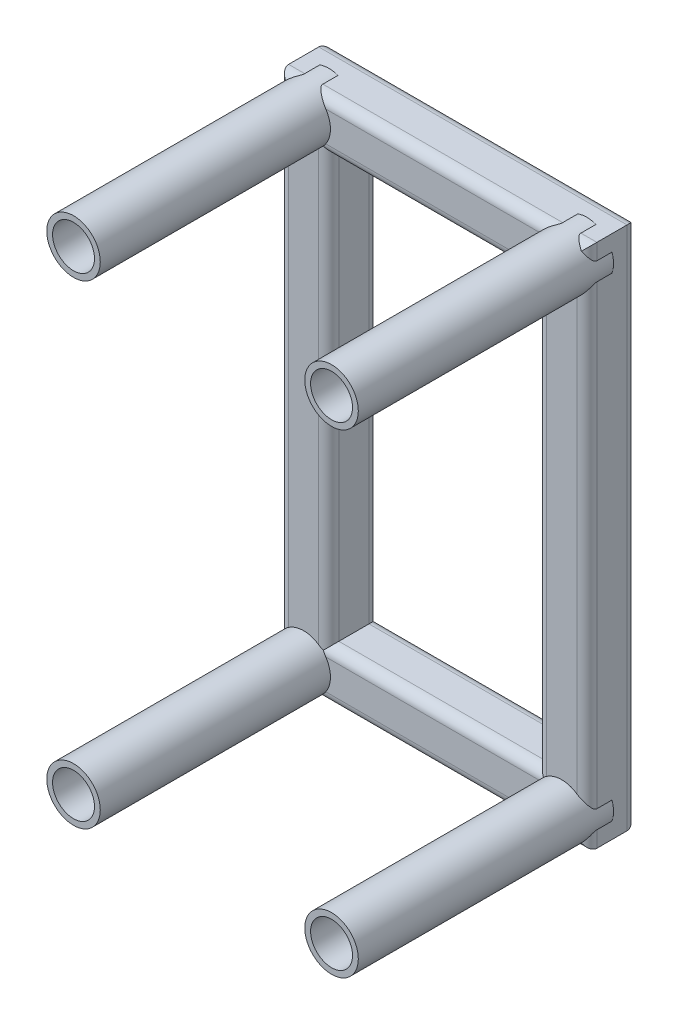
from build123d import *

# Parameters (mm, degrees)
STRUCTURAL_MEMBER1_DEPTH      = 204.012968698
STRUCTURAL_MEMBER1_DEPTH_BACK = 15.142135624
STRUCTURAL_MEMBER1_2_DEPTH    = 132.981628501
STRUCTURAL_MEMBER1_3_DEPTH    = 219.155104322
STRUCTURAL_MEMBER1_4_DEPTH    = 132.981628501
SKETCH19_R                    = 10.65
SKETCH19_R_2                  = 8.35
STRUCTURAL_MEMBER2_DEPTH      = 101.6
SKETCH19_ON_SEGMENT_2_R       = 10.65
SKETCH19_ON_SEGMENT_2_R_2     = 8.35
STRUCTURAL_MEMBER2_2_DEPTH    = 101.6
SKETCH19_ON_SEGMENT_3_R       = 10.65
SKETCH19_ON_SEGMENT_3_R_2     = 8.35
STRUCTURAL_MEMBER2_3_DEPTH    = 101.6
SKETCH19_ON_SEGMENT_4_R       = 10.65
SKETCH19_ON_SEGMENT_4_R_2     = 8.35
STRUCTURAL_MEMBER2_4_DEPTH    = 101.6


with BuildPart() as part:
    # Sketch18 → Structural Member1 (new, two sides)
    with BuildSketch(Plane(origin=(-51.348678627, 94.435416537, 0), x_dir=(1, 0, 0), z_dir=(0, -1, 0))) as structural_member1_sk:
        with BuildLine():
            Line((-6, -10), (6, -10))
            ThreePointArc((6, -10), (8.828427125, -8.828427125), (10, -6))
            Line((10, -6), (10, 6))
            ThreePointArc((10, 6), (8.828427125, 8.828427125), (6, 10))
            Line((6, 10), (-6, 10))
            ThreePointArc((-6, 10), (-8.828427125, 8.828427125), (-10, 6))
            Line((-10, 6), (-10, -6))
            ThreePointArc((-10, -6), (-8.828427125, -8.828427125), (-6, -10))
        make_face()
        with BuildLine():
            Line((-6, -8), (6, -8))
            ThreePointArc((6, -8), (7.414213562, -7.414213562), (8, -6))
            Line((8, -6), (8, 6))
            ThreePointArc((8, 6), (7.414213562, 7.414213562), (6, 8))
            Line((6, 8), (-6, 8))
            ThreePointArc((-6, 8), (-7.414213562, 7.414213562), (-8, 6))
            Line((-8, 6), (-8, -6))
            ThreePointArc((-8, -6), (-7.414213562, -7.414213562), (-6, -8))
        make_face(mode=Mode.SUBTRACT)
    extrude(amount=STRUCTURAL_MEMBER1_DEPTH)
    extrude(structural_member1_sk.sketch, amount=-STRUCTURAL_MEMBER1_DEPTH_BACK)

    # Structural Member1 mitre 1
    split(bisect_by=Plane(origin=(-51.348678627, 94.435416537, 0), x_dir=(0.707106781, -0.707106781, 0), z_dir=(-0.707106781, -0.707106781, 0)), keep=Keep.TOP)

    # Structural Member1 mitre 2
    split(bisect_by=Plane(origin=(-51.348678627, -94.435416537, 0), x_dir=(-0.707106781, -0.707106781, 0), z_dir=(-0.707106781, 0.707106781, 0)), keep=Keep.TOP)


with BuildPart() as body_2:
    # Sketch18 on segment 2 (carried to segment 2) → Structural Member1 2 (new body)
    with BuildSketch(Plane(origin=(-66.490814251, -94.435416537, 0), x_dir=(0, 1, 0), z_dir=(1, 0, 0))):
        with BuildLine():
            Line((-6, -10), (6, -10))
            ThreePointArc((6, -10), (8.828427125, -8.828427125), (10, -6))
            Line((10, -6), (10, 6))
            ThreePointArc((10, 6), (8.828427125, 8.828427125), (6, 10))
            Line((6, 10), (-6, 10))
            ThreePointArc((-6, 10), (-8.828427125, 8.828427125), (-10, 6))
            Line((-10, 6), (-10, -6))
            ThreePointArc((-10, -6), (-8.828427125, -8.828427125), (-6, -10))
        make_face()
        with BuildLine():
            Line((-6, -8), (6, -8))
            ThreePointArc((6, -8), (7.414213562, -7.414213562), (8, -6))
            Line((8, -6), (8, 6))
            ThreePointArc((8, 6), (7.414213562, 7.414213562), (6, 8))
            Line((6, 8), (-6, 8))
            ThreePointArc((-6, 8), (-7.414213562, 7.414213562), (-8, 6))
            Line((-8, 6), (-8, -6))
            ThreePointArc((-8, -6), (-7.414213562, -7.414213562), (-6, -8))
        make_face(mode=Mode.SUBTRACT)
    extrude(amount=STRUCTURAL_MEMBER1_2_DEPTH)

    # Structural Member1 2 mitre 1
    split(bisect_by=Plane(origin=(-51.348678627, -94.435416537, 0), x_dir=(0.707106781, 0.707106781, 0), z_dir=(0.707106781, -0.707106781, 0)), keep=Keep.TOP)

    # Structural Member1 2 mitre 2
    split(bisect_by=Plane(origin=(51.348678627, -94.435416537, 0), x_dir=(0.707106781, -0.707106781, 0), z_dir=(-0.707106781, -0.707106781, 0)), keep=Keep.TOP)


with BuildPart() as body_3:
    # Sketch18 on segment 3 (carried to segment 3) → Structural Member1 3 (new body)
    with BuildSketch(Plane(origin=(51.348678627, -109.577552161, 0), x_dir=(-1, 0, 0), z_dir=(0, 1, 0))):
        with BuildLine():
            Line((-6, -10), (6, -10))
            ThreePointArc((6, -10), (8.828427125, -8.828427125), (10, -6))
            Line((10, -6), (10, 6))
            ThreePointArc((10, 6), (8.828427125, 8.828427125), (6, 10))
            Line((6, 10), (-6, 10))
            ThreePointArc((-6, 10), (-8.828427125, 8.828427125), (-10, 6))
            Line((-10, 6), (-10, -6))
            ThreePointArc((-10, -6), (-8.828427125, -8.828427125), (-6, -10))
        make_face()
        with BuildLine():
            Line((-6, -8), (6, -8))
            ThreePointArc((6, -8), (7.414213562, -7.414213562), (8, -6))
            Line((8, -6), (8, 6))
            ThreePointArc((8, 6), (7.414213562, 7.414213562), (6, 8))
            Line((6, 8), (-6, 8))
            ThreePointArc((-6, 8), (-7.414213562, 7.414213562), (-8, 6))
            Line((-8, 6), (-8, -6))
            ThreePointArc((-8, -6), (-7.414213562, -7.414213562), (-6, -8))
        make_face(mode=Mode.SUBTRACT)
    extrude(amount=STRUCTURAL_MEMBER1_3_DEPTH)

    # Structural Member1 3 mitre 1
    split(bisect_by=Plane(origin=(51.348678627, 94.435416537, 0), x_dir=(0.707106781, 0.707106781, 0), z_dir=(0.707106781, -0.707106781, 0)), keep=Keep.TOP)

    # Structural Member1 3 mitre 2
    split(bisect_by=Plane(origin=(51.348678627, -94.435416537, 0), x_dir=(-0.707106781, 0.707106781, 0), z_dir=(0.707106781, 0.707106781, 0)), keep=Keep.TOP)


with BuildPart() as body_4:
    # Sketch18 on segment 4 (carried to segment 4) → Structural Member1 4 (new body)
    with BuildSketch(Plane(origin=(66.490814251, 94.435416537, 0), x_dir=(0, -1, 0), z_dir=(-1, 0, 0))):
        with BuildLine():
            Line((-6, -10), (6, -10))
            ThreePointArc((6, -10), (8.828427125, -8.828427125), (10, -6))
            Line((10, -6), (10, 6))
            ThreePointArc((10, 6), (8.828427125, 8.828427125), (6, 10))
            Line((6, 10), (-6, 10))
            ThreePointArc((-6, 10), (-8.828427125, 8.828427125), (-10, 6))
            Line((-10, 6), (-10, -6))
            ThreePointArc((-10, -6), (-8.828427125, -8.828427125), (-6, -10))
        make_face()
        with BuildLine():
            Line((-6, -8), (6, -8))
            ThreePointArc((6, -8), (7.414213562, -7.414213562), (8, -6))
            Line((8, -6), (8, 6))
            ThreePointArc((8, 6), (7.414213562, 7.414213562), (6, 8))
            Line((6, 8), (-6, 8))
            ThreePointArc((-6, 8), (-7.414213562, 7.414213562), (-8, 6))
            Line((-8, 6), (-8, -6))
            ThreePointArc((-8, -6), (-7.414213562, -7.414213562), (-6, -8))
        make_face(mode=Mode.SUBTRACT)
    extrude(amount=STRUCTURAL_MEMBER1_4_DEPTH)

    # Structural Member1 4 mitre 1
    split(bisect_by=Plane(origin=(-51.348678627, 94.435416537, 0), x_dir=(-0.707106781, 0.707106781, 0), z_dir=(0.707106781, 0.707106781, 0)), keep=Keep.TOP)

    # Structural Member1 4 mitre 2
    split(bisect_by=Plane(origin=(51.348678627, 94.435416537, 0), x_dir=(-0.707106781, -0.707106781, 0), z_dir=(-0.707106781, 0.707106781, 0)), keep=Keep.TOP)


with BuildPart() as body_5:
    # Sketch19 → Structural Member2 (new body)
    with BuildSketch(Plane(origin=(-51.348678627, 94.435416537, 0), x_dir=(1, 0, 0), z_dir=(0, 0, 1))):
        Circle(SKETCH19_R)
        Circle(SKETCH19_R_2, mode=Mode.SUBTRACT)
    extrude(amount=STRUCTURAL_MEMBER2_DEPTH)


with BuildPart() as body_6:
    # Sketch19 on segment 2 (carried to segment 2) → Structural Member2 2 (new body)
    with BuildSketch(Plane(origin=(-51.348678627, -94.435416537, 0), x_dir=(1, 0, 0), z_dir=(0, 0, 1))):
        Circle(SKETCH19_ON_SEGMENT_2_R)
        Circle(SKETCH19_ON_SEGMENT_2_R_2, mode=Mode.SUBTRACT)
    extrude(amount=STRUCTURAL_MEMBER2_2_DEPTH)


with BuildPart() as body_7:
    # Sketch19 on segment 3 (carried to segment 3) → Structural Member2 3 (new body)
    with BuildSketch(Plane(origin=(51.348678627, 94.435416537, 0), x_dir=(1, 0, 0), z_dir=(0, 0, 1))):
        Circle(SKETCH19_ON_SEGMENT_3_R)
        Circle(SKETCH19_ON_SEGMENT_3_R_2, mode=Mode.SUBTRACT)
    extrude(amount=STRUCTURAL_MEMBER2_3_DEPTH)


with BuildPart() as body_8:
    # Sketch19 on segment 4 (carried to segment 4) → Structural Member2 4 (new body)
    with BuildSketch(Plane(origin=(51.348678627, -94.435416537, 0), x_dir=(1, 0, 0), z_dir=(0, 0, 1))):
        Circle(SKETCH19_ON_SEGMENT_4_R)
        Circle(SKETCH19_ON_SEGMENT_4_R_2, mode=Mode.SUBTRACT)
    extrude(amount=STRUCTURAL_MEMBER2_4_DEPTH)


solid = Compound([part.part, body_2.part, body_3.part, body_4.part, body_5.part, body_6.part, body_7.part, body_8.part])
